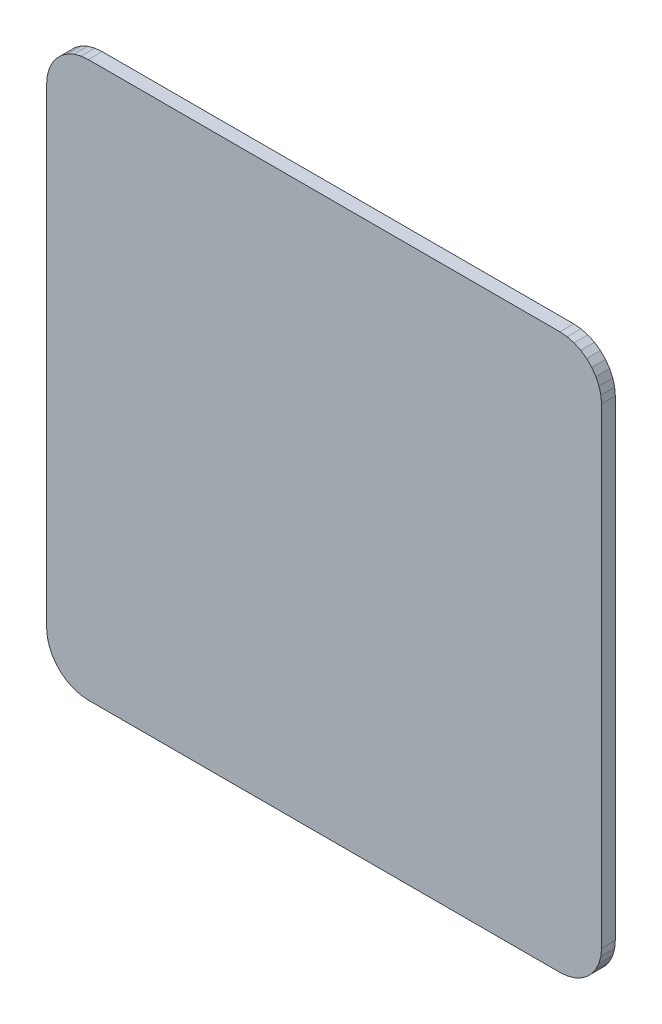
from build123d import *

# Parameters (mm, degrees)
BOARD_DEPTH = 0.9954


with BuildPart() as part:
    # Sketch1 → Board (new body)
    with BuildSketch(Plane.XY):
        Polygon((238.7374, 111.8768), (272.7374, 111.8768), (273.25834, 111.92238), (273.76346, 112.05772), (274.2374, 112.27873), (274.66577, 112.57866), (275.03553, 112.94844), (275.33547, 113.3768), (275.55647, 113.85075), (275.69182, 114.35586), (275.7374, 114.8768), (275.7374, 148.8768), (275.69182, 149.39774), (275.55647, 149.90287), (275.33547, 150.3768), (275.03553, 150.80516), (274.66577, 151.17494), (274.2374, 151.47488), (273.76346, 151.69588), (273.25834, 151.83122), (272.7374, 151.8768), (238.7374, 151.8768), (238.21646, 151.83122), (237.71135, 151.69588), (237.2374, 151.47488), (236.80904, 151.17494), (236.43927, 150.80516), (236.13933, 150.3768), (235.91833, 149.90287), (235.78298, 149.39774), (235.7374, 148.8768), (235.7374, 114.8768), (235.78298, 114.35586), (235.91833, 113.85075), (236.13933, 113.3768), (236.43927, 112.94844), (236.80904, 112.57866), (237.2374, 112.27873), (237.71135, 112.05772), (238.21646, 111.92238), align=None)
    extrude(amount=BOARD_DEPTH)


solid = part.part
